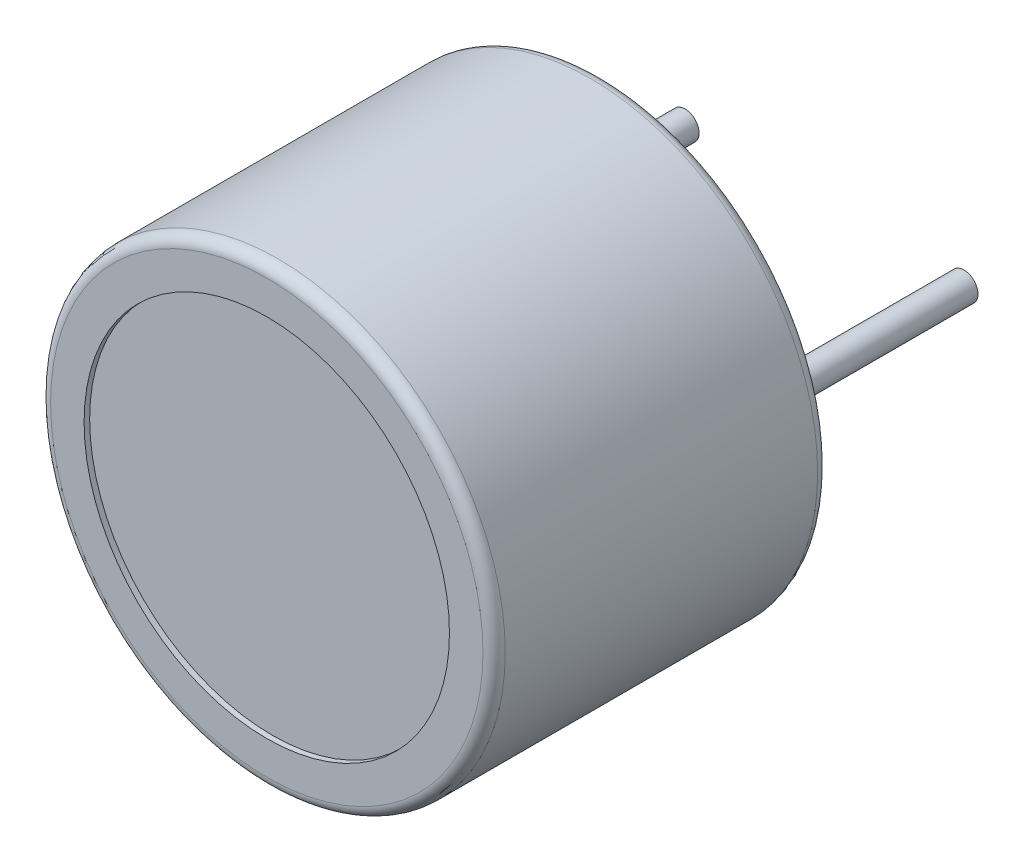
from build123d import *

# Parameters (mm, degrees)
ESQCORPS_R   = 8.15
CORPS_DEPTH  = 12
ESQPATTES_R  = 0.5
PATTES_DEPTH = 8
CONG_1_R     = 0.4
ESQDEVANT_R  = 6.55
DEVANT_DEPTH = 0.2


with BuildPart() as part:
    # EsqCorps → Corps (new body)
    with BuildSketch(Plane.XY):
        Circle(ESQCORPS_R)
    extrude(amount=CORPS_DEPTH)

    # EsqPattes → Pattes (add)
    with BuildSketch(Plane(origin=(0, 0, 0), x_dir=(-1, 0, 0), z_dir=(0, 0, -1))):
        with Locations((-5, 0)):
            Circle(ESQPATTES_R)
        with Locations((5, 0)):
            Circle(ESQPATTES_R)
    extrude(amount=PATTES_DEPTH)

    # Congé1
    cong_1_edges = [part.edges().sort_by_distance(p)[0] for p in [
        (-8.15, 0, 0),
        (-8.15, 0, 12),
        (5.5, 0, 0),
        (-4.5, 0, 0),
    ]]
    fillet(cong_1_edges, radius=CONG_1_R)

    # EsqDevant → Devant (cut)
    with BuildSketch(Plane.XY.offset(12)):
        Circle(ESQDEVANT_R)
    extrude(amount=-DEVANT_DEPTH, mode=Mode.SUBTRACT)


solid = part.part
